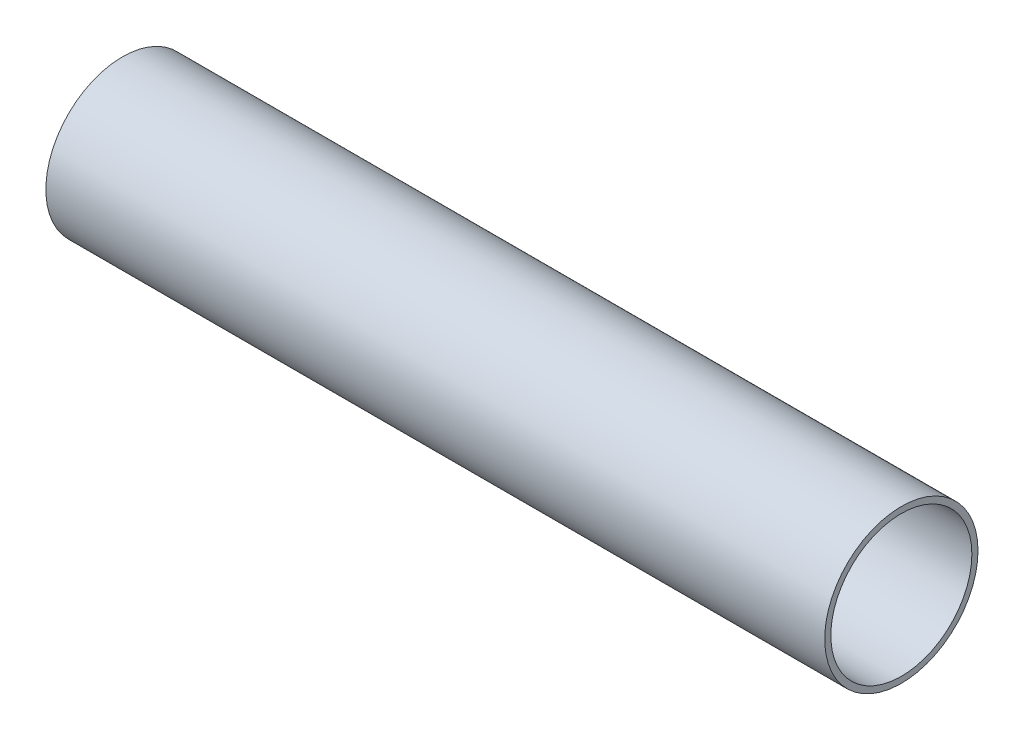
from build123d import *

# Parameters (mm, degrees)
SKETCH1_R           = 12.5
SKETCH1_R_2         = 11.5
BOSS_EXTRUDE1_DEPTH = 127


with BuildPart() as part:
    # Sketch1 → Boss-Extrude1 (new body)
    with BuildSketch(Plane(origin=(0, 0, 0), x_dir=(0, 0, -1), z_dir=(1, 0, 0))):
        Circle(SKETCH1_R)
        Circle(SKETCH1_R_2, mode=Mode.SUBTRACT)
    extrude(amount=BOSS_EXTRUDE1_DEPTH)


solid = part.part
